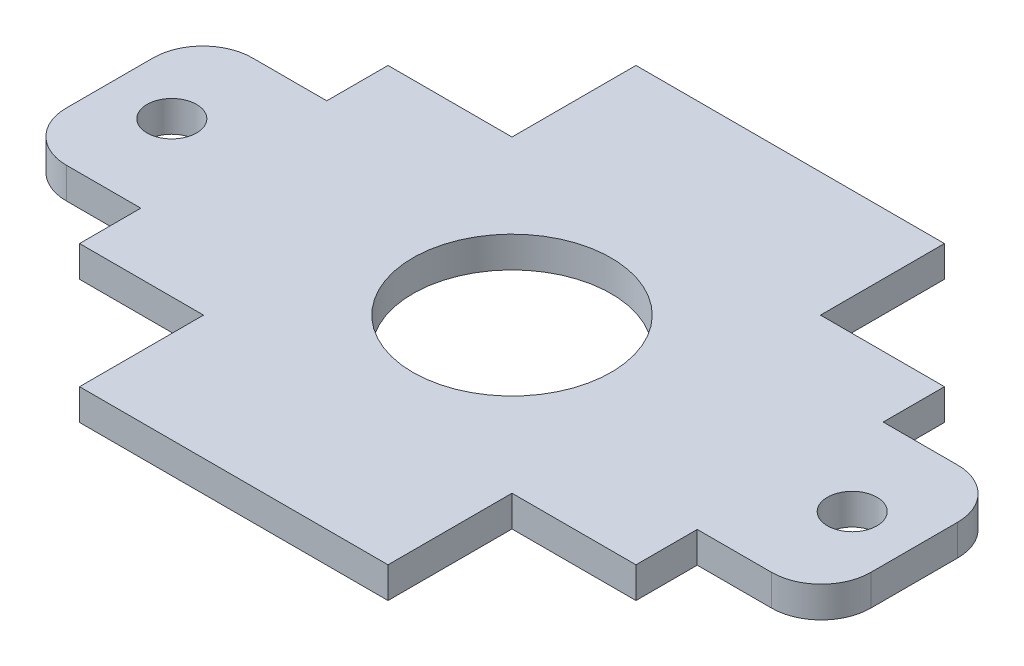
from build123d import *

# Parameters (mm, degrees)
SKETCH1_R           = 10.16
SKETCH1_R_2         = 2.54
BOSS_EXTRUDE1_DEPTH = 3.175


with BuildPart() as part:
    # Sketch1 → Boss-Extrude1 (new body)
    with BuildSketch(Plane(origin=(0, 0, 0), x_dir=(1, 0, 0), z_dir=(0, 1, 0))):
        with BuildLine():
            Line((-28.4999938, 15.7999938), (-28.4999938, 9.525))
            Line((-28.4999938, 9.525), (-36.1199938, 9.525))
            ThreePointArc((-36.1199938, 9.525), (-39.712096248, 8.037102448), (-41.1999938, 4.445))
            Line((-41.1999938, 4.445), (-41.1999938, -4.445))
            ThreePointArc((-41.1999938, -4.445), (-39.712096248, -8.037102448), (-36.1199938, -9.525))
            Line((-36.1199938, -9.525), (-28.4999938, -9.525))
            Line((-28.4999938, -9.525), (-28.4999938, -15.7999938))
            Line((-28.4999938, -15.7999938), (-15.7999938, -15.7999938))
            Line((-15.7999938, -15.7999938), (-15.7999938, -28.4999938))
            Line((-15.7999938, -28.4999938), (15.7999938, -28.4999938))
            Line((15.7999938, -28.4999938), (15.7999938, -15.7999938))
            Line((15.7999938, -15.7999938), (28.4999938, -15.7999938))
            Line((28.4999938, -15.7999938), (28.4999938, -9.525))
            Line((28.4999938, -9.525), (36.1199938, -9.525))
            ThreePointArc((36.1199938, -9.525), (39.712096248, -8.037102448), (41.1999938, -4.445))
            Line((41.1999938, -4.445), (41.1999938, 4.445))
            ThreePointArc((41.1999938, 4.445), (39.712096248, 8.037102448), (36.1199938, 9.525))
            Line((36.1199938, 9.525), (28.4999938, 9.525))
            Line((28.4999938, 9.525), (28.4999938, 15.7999938))
            Line((28.4999938, 15.7999938), (15.7999938, 15.7999938))
            Line((15.7999938, 15.7999938), (15.7999938, 28.4999938))
            Line((15.7999938, 28.4999938), (-15.7999938, 28.4999938))
            Line((-15.7999938, 28.4999938), (-15.7999938, 15.7999938))
            Line((-15.7999938, 15.7999938), (-28.4999938, 15.7999938))
        make_face()
        Circle(SKETCH1_R, mode=Mode.SUBTRACT)
        with Locations((-34.8499938, 0)):
            Circle(SKETCH1_R_2, mode=Mode.SUBTRACT)
        with Locations((34.8499938, 0)):
            Circle(SKETCH1_R_2, mode=Mode.SUBTRACT)
    extrude(amount=BOSS_EXTRUDE1_DEPTH)


solid = part.part
